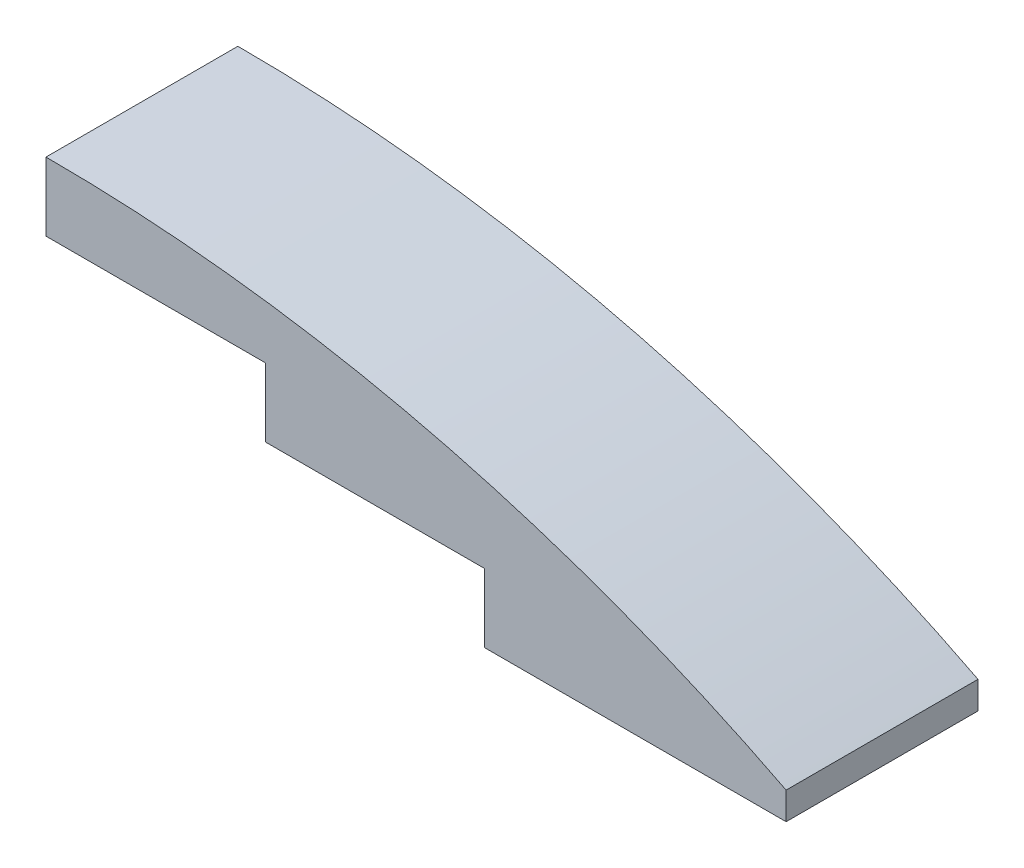
from build123d import *

# Parameters (mm, degrees)
BOSS_EXTRUDE1_DEPTH     = 4.445
CUT_EXTRUDE2_REACH      = 37.155
CUT_EXTRUDE2_END_RADIUS = 74.075192308
SKETCH2_W               = 9.8425
SKETCH2_H               = 8.255
CUT_EXTRUDE3_REACH      = 37.155
CUT_EXTRUDE3_END_RADIUS = 74.075192308
SKETCH3_W               = 9.8425
SKETCH3_H               = 8.255
CUT_EXTRUDE5_REACH      = 37.865
CUT_EXTRUDE5_END_RADIUS = 75.345192308
SKETCH4_W               = 13.335
SKETCH4_H               = 8.255


with BuildPart() as part:
    # Sketch1 → Boss-Extrude1 (new, symmetric)
    with BuildSketch(Plane.XY):
        with BuildLine():
            Line((0, 0), (0, -3.175))
            Line((0, -3.175), (10.16, -3.175))
            Line((10.16, -3.175), (10.16, -6.35))
            Line((10.16, -6.35), (20.32, -6.35))
            Line((20.32, -6.35), (20.32, -9.525))
            Line((20.32, -9.525), (34.29, -9.525))
            Line((34.29, -9.525), (34.29, -8.255))
            ThreePointArc((34.29, -8.255), (17.634831478, -2.0928154), (0, 0))
        make_face()
    extrude(amount=BOSS_EXTRUDE1_DEPTH, both=True)

    # Cut-Extrude2: up to this cylinder (the profile starts inside it)
    cut_extrude2_end = Plane(origin=(0, -75.345192308, 0), z_dir=(0, 0, -1)) * Cylinder(CUT_EXTRUDE2_END_RADIUS, 223.460384615, mode=Mode.PRIVATE)
    # Sketch2 → Cut-Extrude2 (cut, up to the surface)
    with BuildSketch(Plane.XZ.offset(3.175), mode=Mode.PRIVATE) as cut_extrude2_sk1:
        with Locations((5.23875, 0)):
            Rectangle(SKETCH2_W, SKETCH2_H)
    cut_extrude2_tool1 = extrude(cut_extrude2_sk1.sketch, amount=-CUT_EXTRUDE2_REACH, mode=Mode.PRIVATE) & cut_extrude2_end
    add(cut_extrude2_tool1.solids().sort_by_distance((5.23875, -3.175, 0))[0], mode=Mode.SUBTRACT)

    # Cut-Extrude3: up to this cylinder (the profile starts inside it)
    cut_extrude3_end = Plane(origin=(0, -75.345192308, 0), z_dir=(0, 0, -1)) * Cylinder(CUT_EXTRUDE3_END_RADIUS, 223.460384615, mode=Mode.PRIVATE)
    # Sketch3 → Cut-Extrude3 (cut, up to the surface)
    with BuildSketch(Plane.XZ.offset(6.35), mode=Mode.PRIVATE) as cut_extrude3_sk1:
        with Locations((15.39875, 0)):
            Rectangle(SKETCH3_W, SKETCH3_H)
    cut_extrude3_tool1 = extrude(cut_extrude3_sk1.sketch, amount=-CUT_EXTRUDE3_REACH, mode=Mode.PRIVATE) & cut_extrude3_end
    add(cut_extrude3_tool1.solids().sort_by_distance((15.39875, -6.35, 0))[0], mode=Mode.SUBTRACT)

    # Cut-Extrude5: up to this cylinder (the profile starts inside it)
    cut_extrude5_end = Plane(origin=(0, -76.615192308, 0), z_dir=(0, 0, -1)) * Cylinder(CUT_EXTRUDE5_END_RADIUS, 227.420384615, mode=Mode.PRIVATE)
    # Sketch4 → Cut-Extrude5 (cut, up to the surface)
    with BuildSketch(Plane.XZ.offset(9.525), mode=Mode.PRIVATE) as cut_extrude5_sk1:
        with Locations((27.305, 0)):
            Rectangle(SKETCH4_W, SKETCH4_H)
    cut_extrude5_tool1 = extrude(cut_extrude5_sk1.sketch, amount=-CUT_EXTRUDE5_REACH, mode=Mode.PRIVATE) & cut_extrude5_end
    add(cut_extrude5_tool1.solids().sort_by_distance((27.305, -9.525, 0))[0], mode=Mode.SUBTRACT)


solid = part.part
